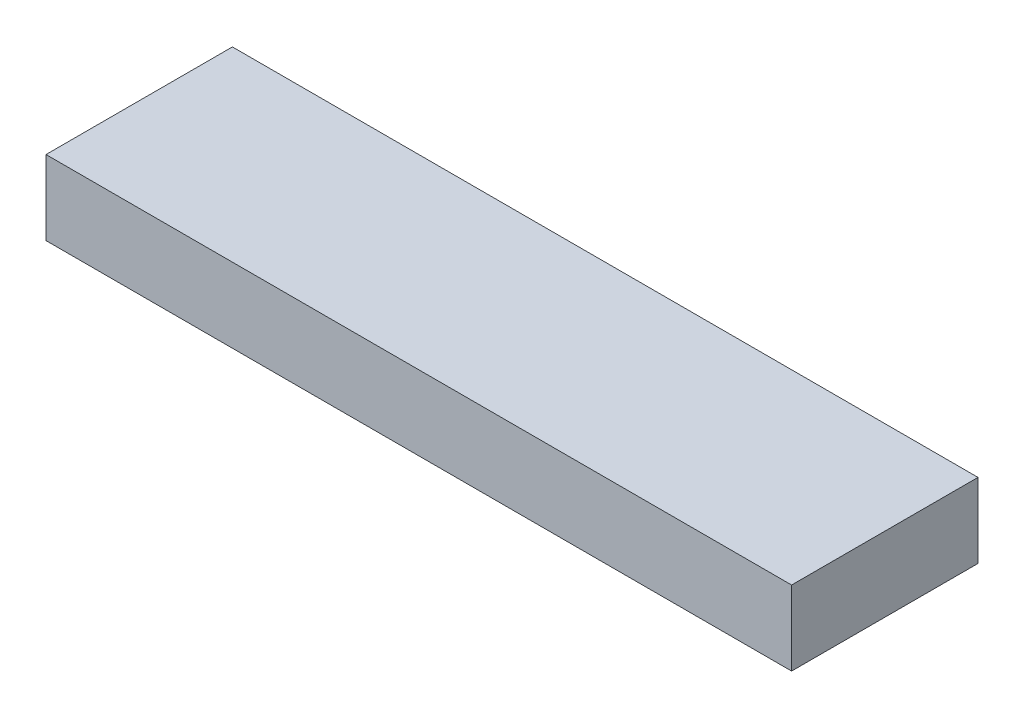
from build123d import *

# Parameters (mm, degrees)
SKETCH1_W           = 20
SKETCH1_H           = 5
BOSS_EXTRUDE1_DEPTH = 1
SKETCH1_3_W         = 20
SKETCH1_3_H         = 5
SKETCH1_3_W_2       = 18
SKETCH1_3_H_2       = 3
SKETCH1_3_R         = 1
BOSS_EXTRUDE2_DEPTH = 1


with BuildPart() as part:
    # Sketch1 → Boss-Extrude1 (new body)
    with BuildSketch(Plane(origin=(0, 0, 0), x_dir=(1, 0, 0), z_dir=(0, 1, 0))):
        Rectangle(SKETCH1_W, SKETCH1_H)
    extrude(amount=BOSS_EXTRUDE1_DEPTH)

    # Sketch1_3 → Boss-Extrude2 (add)
    # profile 1 of 4: a face of its own
    with BuildSketch(Plane(origin=(0, 0, 0), x_dir=(1, 0, 0), z_dir=(0, 1, 0))):
        Rectangle(SKETCH1_3_W, SKETCH1_3_H)
        Rectangle(SKETCH1_3_W_2, SKETCH1_3_H_2, mode=Mode.SUBTRACT)
    # profile 2 of 4: a face of its own
    with BuildSketch(Plane(origin=(0, 0, 0), x_dir=(1, 0, 0), z_dir=(0, 1, 0))):
        with Locations((-5, 0)):
            Circle(SKETCH1_3_R)
    # profile 3 of 4: a face of its own
    with BuildSketch(Plane(origin=(0, 0, 0), x_dir=(1, 0, 0), z_dir=(0, 1, 0))):
        Circle(SKETCH1_3_R)
    # profile 4 of 4: a face of its own
    with BuildSketch(Plane(origin=(0, 0, 0), x_dir=(1, 0, 0), z_dir=(0, 1, 0))):
        with Locations((5, 0)):
            Circle(SKETCH1_3_R)
    extrude(amount=-BOSS_EXTRUDE2_DEPTH)


solid = part.part
